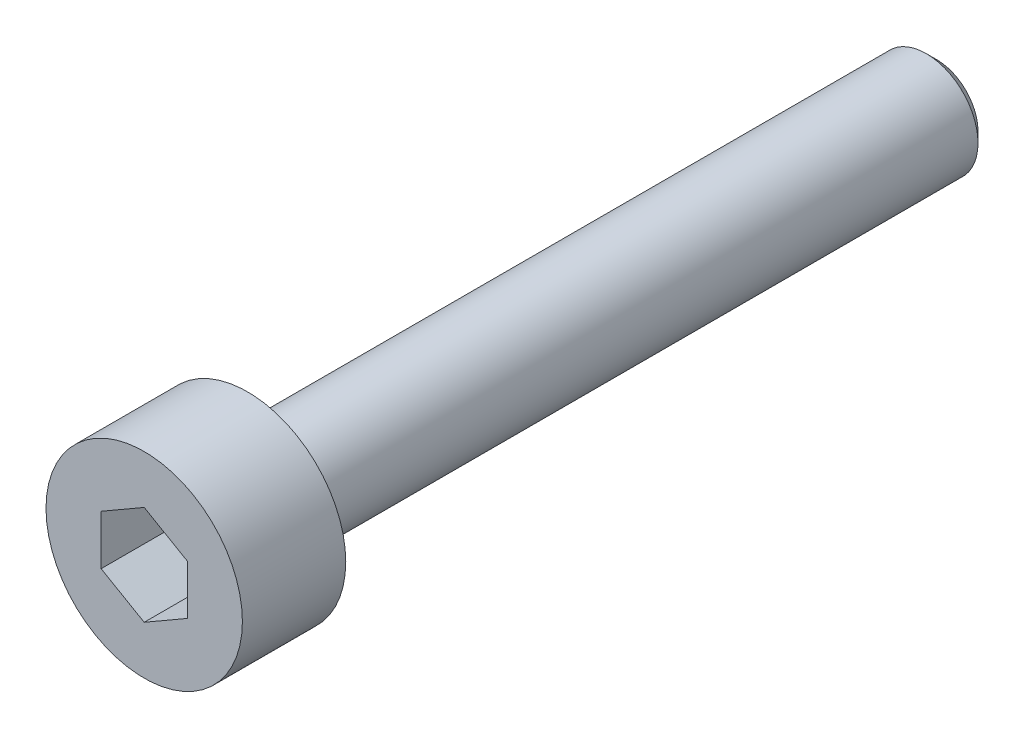
from build123d import *

# Parameters (mm, degrees)
SKETCH1_R           = 2.85
BOSS_EXTRUDE1_DEPTH = 3
SKETCH2_R           = 1.5
BOSS_EXTRUDE2_DEPTH = 20
CHAMFER1_SIZE       = 0.3
CUT_EXTRUDE1_DEPTH  = 2


with BuildPart() as part:
    # Sketch1 → Boss-Extrude1 (new body)
    with BuildSketch(Plane.XY):
        Circle(SKETCH1_R)
    extrude(amount=BOSS_EXTRUDE1_DEPTH)

    # Sketch2 → Boss-Extrude2 (add)
    with BuildSketch(Plane(origin=(0, 0, 0), x_dir=(-1, 0, 0), z_dir=(0, 0, -1))):
        Circle(SKETCH2_R)
    extrude(amount=BOSS_EXTRUDE2_DEPTH)

    # Chamfer1
    chamfer1_edges = [part.edges().sort_by_distance(p)[0] for p in [
        (1.5, 0, -20),
    ]]
    chamfer(chamfer1_edges, length=CHAMFER1_SIZE)

    # Sketch3 → Cut-Extrude1 (cut)
    with BuildSketch(Plane.XY.offset(3)):
        Polygon((0, 1.443375673), (-1.25, 0.721687836), (-1.25, -0.721687836), (0, -1.443375673), (1.25, -0.721687836), (1.25, 0.721687836), align=None)
    extrude(amount=-CUT_EXTRUDE1_DEPTH, mode=Mode.SUBTRACT)


solid = part.part
